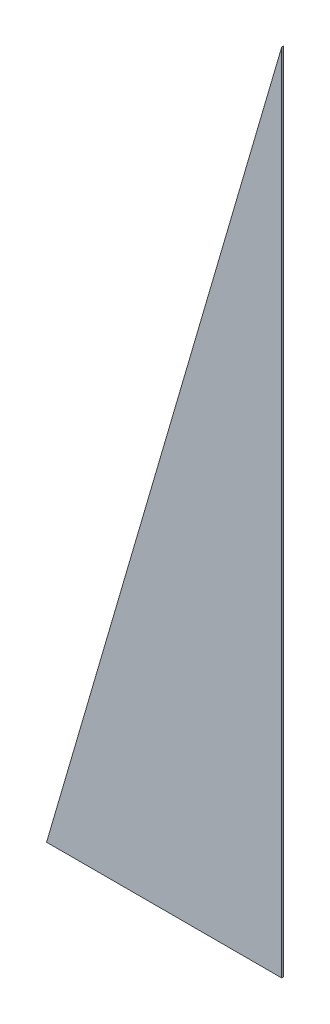
from build123d import *

# Parameters (mm, degrees)
BOSS_EXTRUDE1_DEPTH = 2.54


with BuildPart() as part:
    # Sketch1 → Boss-Extrude1 (new body)
    with BuildSketch(Plane.XY):
        Polygon((0, 0), (0, 1219.2), (-355.6, 0), align=None)
    extrude(amount=BOSS_EXTRUDE1_DEPTH)


solid = part.part
